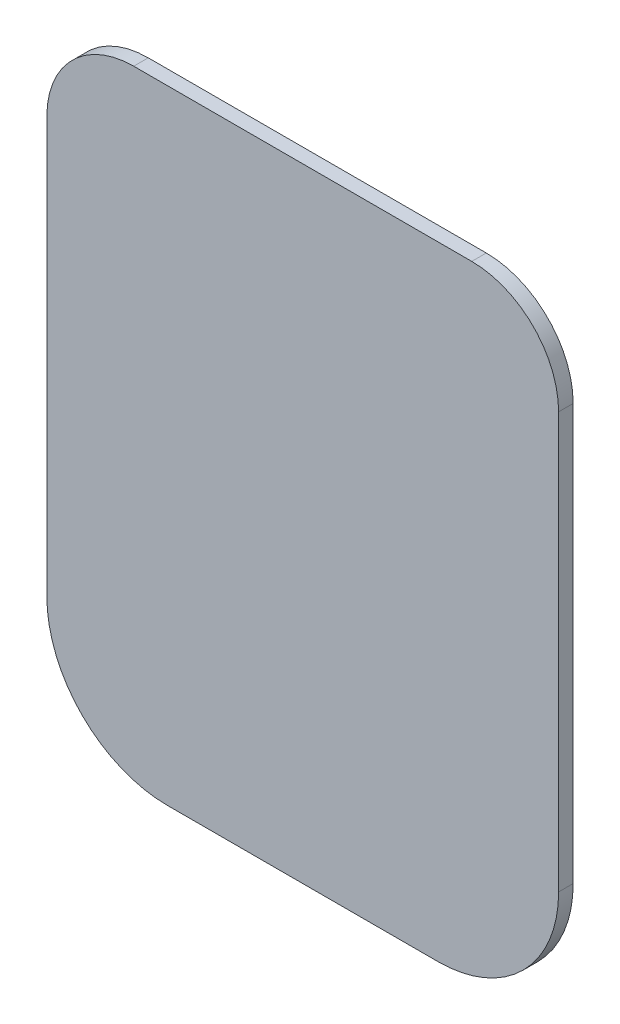
from build123d import *

# Parameters (mm, degrees)
BOSS_EXTRUDE1_DEPTH = 4.3


with BuildPart() as part:
    # Sketch1 → Boss-Extrude1 (new body)
    with BuildSketch(Plane.XY):
        with BuildLine():
            Line((0.5, -92.2), (40, -92.2))
            ThreePointArc((40, -92.2), (65.243712088, -81.743712088), (75.7, -56.5))
            Line((75.7, -56.5), (75.7, 66.5))
            ThreePointArc((75.7, 66.5), (68.172644276, 84.672644276), (50, 92.2))
            Line((50, 92.2), (-50, 92.2))
            ThreePointArc((-50, 92.2), (-68.172644276, 84.672644276), (-75.7, 66.5))
            Line((-75.7, 66.5), (-75.7, -56.5))
            ThreePointArc((-75.7, -56.5), (-65.243712088, -81.743712088), (-40, -92.2))
            Line((-40, -92.2), (-0.5, -92.2))
            Line((-0.5, -92.2), (0.5, -92.2))
        make_face()
    extrude(amount=BOSS_EXTRUDE1_DEPTH)


solid = part.part
